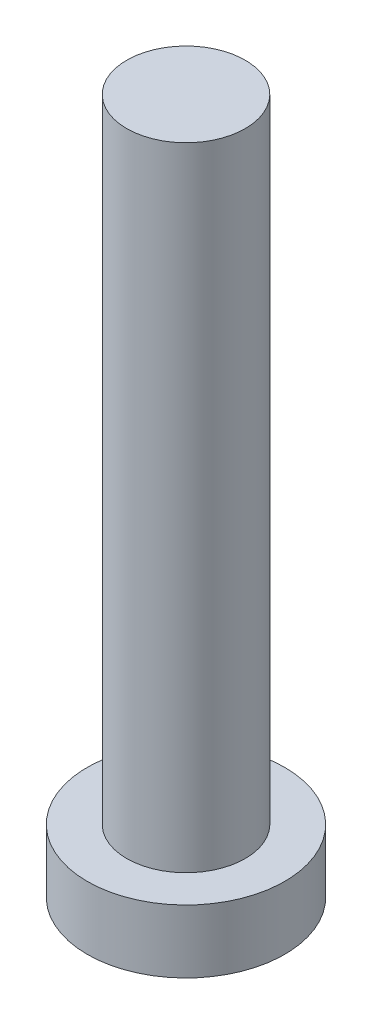
from build123d import *

# Parameters (mm, degrees)
SKETCH_1_R          = 2.5
EXTRUDE_1_DEPTH     = 1.6
SKETCH_2_R          = 1.5
EXTRUDE_2_DEPTH     = 16
CUT_EXTRUDE_1_DEPTH = 1


with BuildPart() as part:
    # 草图1 → 凸台-拉伸1 (new body)
    with BuildSketch(Plane(origin=(0, 0, 0), x_dir=(1, 0, 0), z_dir=(0, 1, 0))):
        Circle(SKETCH_1_R)
    extrude(amount=EXTRUDE_1_DEPTH)

    # 草图2 → 凸台-拉伸2 (add)
    with BuildSketch(Plane(origin=(0, 1.6, 0), x_dir=(1, 0, 0), z_dir=(0, 1, 0))):
        Circle(SKETCH_2_R)
    extrude(amount=EXTRUDE_2_DEPTH)

    # 草图3 → 切除-拉伸1 (cut)
    with BuildSketch(Plane.XZ):
        with BuildLine():
            Line((-0.5, 1), (-0.5, 1.75))
            Line((-0.5, 1.75), (0.5, 1.75))
            Line((0.5, 1.75), (0.5, 1))
            ThreePointArc((0.5, 1), (0.646446609, 0.646446609), (1, 0.5))
            Line((1, 0.5), (1.75, 0.5))
            Line((1.75, 0.5), (1.75, -0.5))
            Line((1.75, -0.5), (1, -0.5))
            ThreePointArc((1, -0.5), (0.646446609, -0.646446609), (0.5, -1))
            Line((0.5, -1), (0.5, -1.75))
            Line((0.5, -1.75), (-0.5, -1.75))
            Line((-0.5, -1.75), (-0.5, -1))
            ThreePointArc((-0.5, -1), (-0.646446609, -0.646446609), (-1, -0.5))
            Line((-1, -0.5), (-1.75, -0.5))
            Line((-1.75, -0.5), (-1.75, 0.5))
            Line((-1.75, 0.5), (-1, 0.5))
            ThreePointArc((-1, 0.5), (-0.646446609, 0.646446609), (-0.5, 1))
        make_face()
    extrude(amount=-CUT_EXTRUDE_1_DEPTH, mode=Mode.SUBTRACT)


solid = part.part
